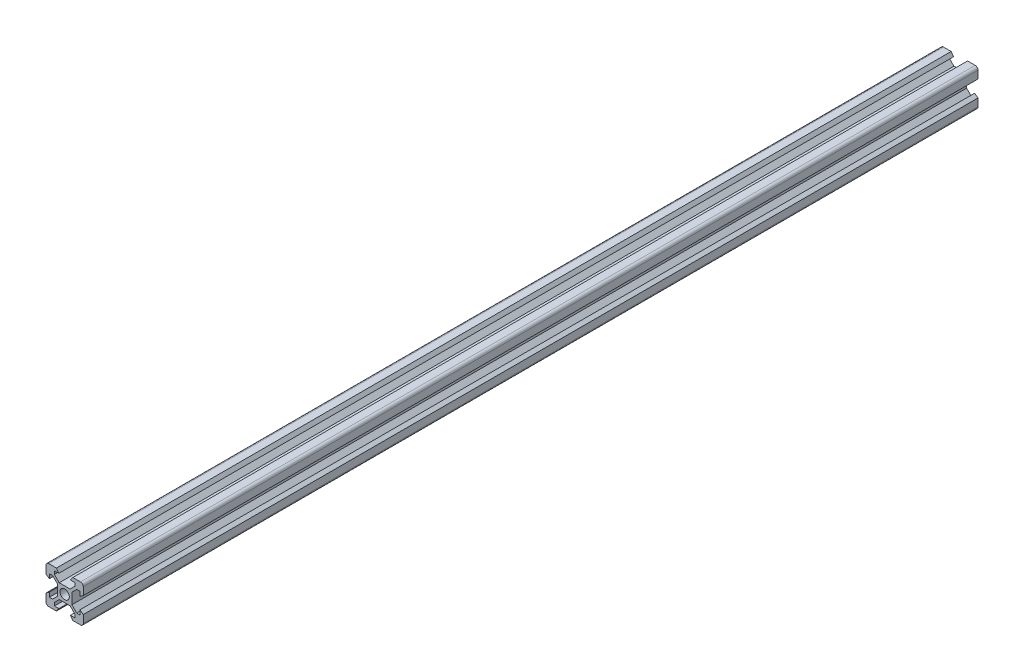
from build123d import *

# Parameters (mm, degrees)
SKETCH_1_R      = 2.5
EXTRUDE_1_DEPTH = 480


with BuildPart() as part:
    # 草图1 → 凸台-拉伸1 (new body)
    with BuildSketch(Plane.XY):
        with BuildLine():
            Line((14.8, 34.821428571), (18.9, 34.821428571))
            Line((18.9, 34.821428571), (20.2, 33.021428571))
            Line((20.2, 33.021428571), (17.8, 33.021428571))
            Line((17.8, 33.021428571), (17.8, 31.311378065))
            Line((17.8, 31.311378065), (20.389949494, 28.721428571))
            Line((20.389949494, 28.721428571), (26.210050506, 28.721428571))
            Line((26.210050506, 28.721428571), (28.8, 31.311378065))
            Line((28.8, 31.311378065), (28.8, 33.021428571))
            Line((28.8, 33.021428571), (26.4, 33.021428571))
            Line((26.4, 33.021428571), (27.7, 34.821428571))
            Line((27.7, 34.821428571), (31.8, 34.821428571))
            ThreePointArc((31.8, 34.821428571), (32.860660172, 34.382088743), (33.3, 33.321428571))
            Line((33.3, 33.321428571), (33.3, 29.221428571))
            Line((33.3, 29.221428571), (31.5, 27.921428571))
            Line((31.5, 27.921428571), (31.5, 30.321428571))
            Line((31.5, 30.321428571), (29.789949494, 30.321428571))
            Line((29.789949494, 30.321428571), (27.2, 27.731479078))
            Line((27.2, 27.731479078), (27.2, 21.911378065))
            Line((27.2, 21.911378065), (29.789949494, 19.321428571))
            Line((29.789949494, 19.321428571), (31.5, 19.321428571))
            Line((31.5, 19.321428571), (31.5, 21.721428571))
            Line((31.5, 21.721428571), (33.3, 20.421428571))
            Line((33.3, 20.421428571), (33.3, 16.321428571))
            ThreePointArc((33.3, 16.321428571), (32.860660172, 15.2607684), (31.8, 14.821428571))
            Line((31.8, 14.821428571), (27.7, 14.821428571))
            Line((27.7, 14.821428571), (26.4, 16.621428571))
            Line((26.4, 16.621428571), (28.8, 16.621428571))
            Line((28.8, 16.621428571), (28.8, 18.331479078))
            Line((28.8, 18.331479078), (26.210050506, 20.921428571))
            Line((26.210050506, 20.921428571), (20.389949494, 20.921428571))
            Line((20.389949494, 20.921428571), (17.8, 18.331479078))
            Line((17.8, 18.331479078), (17.8, 16.621428571))
            Line((17.8, 16.621428571), (20.2, 16.621428571))
            Line((20.2, 16.621428571), (18.9, 14.821428571))
            Line((18.9, 14.821428571), (14.8, 14.821428571))
            ThreePointArc((14.8, 14.821428571), (13.739339828, 15.2607684), (13.3, 16.321428571))
            Line((13.3, 16.321428571), (13.3, 20.421428571))
            Line((13.3, 20.421428571), (15.1, 21.721428571))
            Line((15.1, 21.721428571), (15.1, 19.321428571))
            Line((15.1, 19.321428571), (16.810050506, 19.321428571))
            Line((16.810050506, 19.321428571), (19.4, 21.911378065))
            Line((19.4, 21.911378065), (19.4, 27.731479078))
            Line((19.4, 27.731479078), (16.810050506, 30.321428571))
            Line((16.810050506, 30.321428571), (15.1, 30.321428571))
            Line((15.1, 30.321428571), (15.1, 27.921428571))
            Line((15.1, 27.921428571), (13.3, 29.221428571))
            Line((13.3, 29.221428571), (13.3, 33.321428571))
            ThreePointArc((13.3, 33.321428571), (13.739339828, 34.382088743), (14.8, 34.821428571))
        make_face()
        with Locations((23.3, 24.821428571)):
            Circle(SKETCH_1_R, mode=Mode.SUBTRACT)
    extrude(amount=EXTRUDE_1_DEPTH)


solid = part.part
